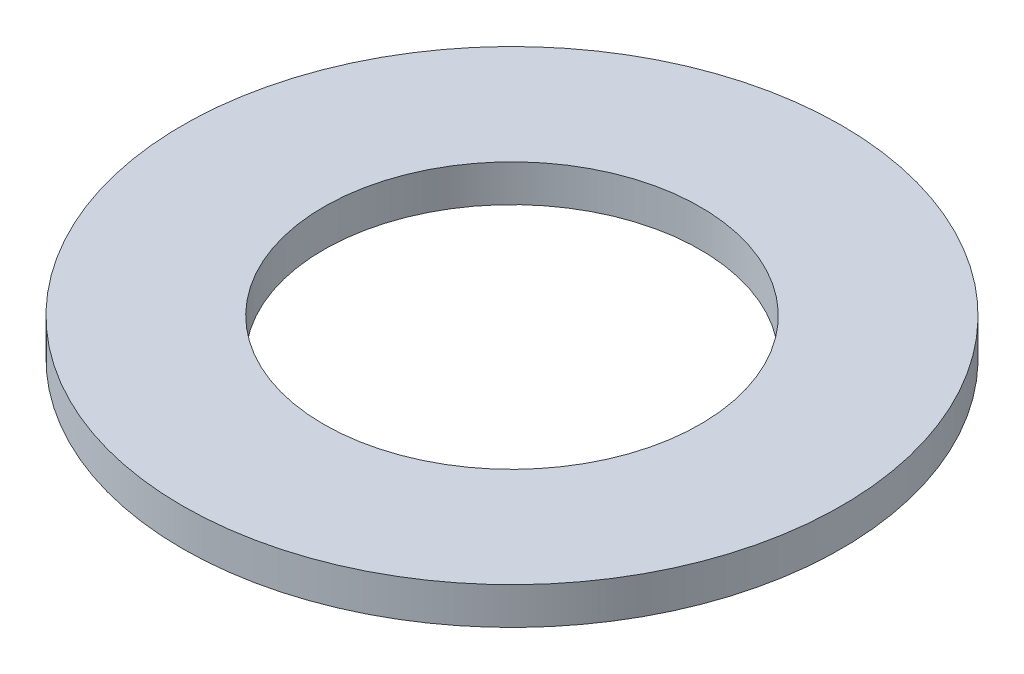
from build123d import *

# Parameters (mm, degrees)
SKETCH2_R           = 88.9
BOSS_EXTRUDE1_DEPTH = 10
SKETCH4_R           = 50.8
CUT_EXTRUDE1_DEPTH  = 15


with BuildPart() as part:
    # Sketch2 → Boss-Extrude1 (new body)
    with BuildSketch(Plane(origin=(0, 0, 0), x_dir=(1, 0, 0), z_dir=(0, 1, 0))):
        Circle(SKETCH2_R)
    extrude(amount=BOSS_EXTRUDE1_DEPTH)

    # Sketch4 → Cut-Extrude1 (cut)
    with BuildSketch(Plane(origin=(0, 0, 0), x_dir=(1, 0, 0), z_dir=(0, 1, 0))):
        Circle(SKETCH4_R)
    extrude(amount=CUT_EXTRUDE1_DEPTH, mode=Mode.SUBTRACT)


solid = part.part
